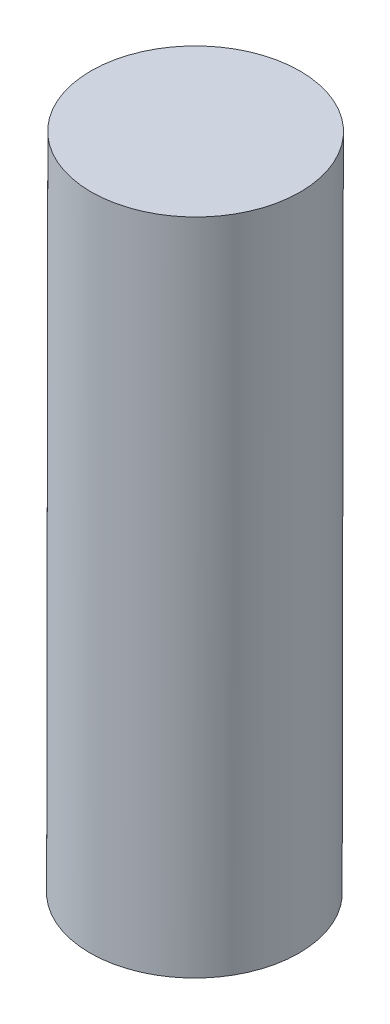
from build123d import *

# Parameters (mm, degrees)
SWEEP1_PROFILE_R = 4.699


with BuildPart() as part:
    # Sweep1: sweep along a curve in space
    with BuildLine() as sweep1_path:
        Line((-266.617064338, 133.219904817, 163.321796793), (-266.564789525, 162.850522994, 163.321796827))
    # Sweep1 profile (on start of the path) → Sweep1 (sweep)
    with BuildSketch(Plane(origin=(-266.617064338, 133.219904817, 163.321796793), x_dir=(0.999998444, -0.001764213, 0), z_dir=(0.001764213, 0.999998444, 1e-09))):
        Circle(SWEEP1_PROFILE_R)
    sweep(path=sweep1_path.line)


solid = part.part
